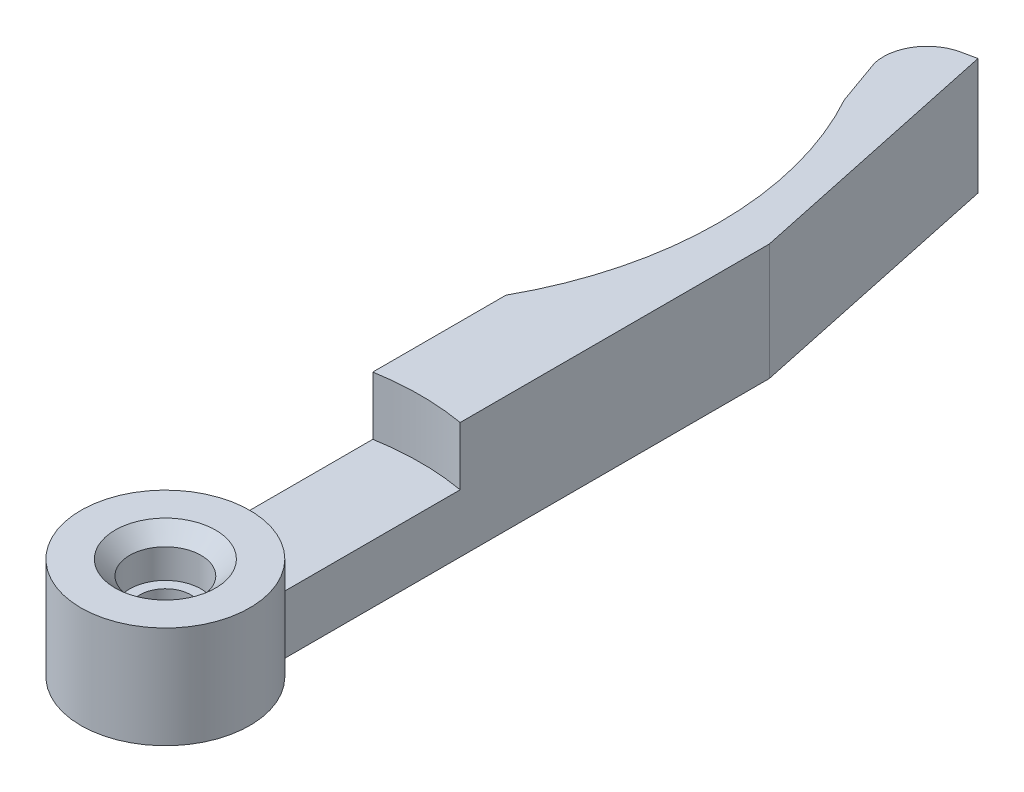
from build123d import *

# Parameters (mm, degrees)
BOSS_EXTRU_1_DEPTH      = 8
ESQUISSE2_R             = 2.45
ENL_V_MAT_EXTRU_1_DEPTH = 4
ENL_V_MAT_EXTRU_2_REACH = 59.094
ESQUISSE3_R             = 1.75
ESQUISSE4_R             = 3.75
ENL_V_MAT_EXTRU_3_DEPTH = 2.5
ENL_V_MAT_EXTRU_4_DEPTH = 4
ESQUISSE7_R             = 5.8
ENL_V_MAT_EXTRU_5_DEPTH = 1
CHANFREIN1_SIZE         = 1


with BuildPart() as part:
    # Esquisse1 → Boss.-Extru.1 (new body)
    with BuildSketch(Plane(origin=(0, 0, 0), x_dir=(1, 0, 0), z_dir=(0, 1, 0))):
        with BuildLine():
            Line((-3, 26.381049961), (-3, 4.963869458))
            ThreePointArc((-3, 4.963869458), (0, -5.8), (3, 4.963869458))
            Line((3, 4.963869458), (3, 38.463869458))
            Line((3, 38.463869458), (-0.867157449, 56.657414832))
            Line((-0.867157449, 56.657414832), (-1.84530505, 56.449503141))
            ThreePointArc((-1.84530505, 56.449503141), (-3.756758837, 55.119060789), (-4.140414176, 52.821988519))
            Line((-4.140414176, 52.821988519), (-3, 49.618950039))
            ThreePointArc((-3, 49.618950039), (0, 38), (-3, 26.381049961))
        make_face()
    extrude(amount=BOSS_EXTRU_1_DEPTH)

    # Esquisse2 → Enlèv. mat.-Extru.1 (cut)
    with BuildSketch(Plane(origin=(0, 8, 0), x_dir=(1, 0, 0), z_dir=(0, 1, 0))):
        with Locations(Location((0, 0, 0), (0, 0, 270))):
            Circle(ESQUISSE2_R)
    extrude(amount=-ENL_V_MAT_EXTRU_1_DEPTH, mode=Mode.SUBTRACT)

    # Esquisse3 → Enlèv. mat.-Extru.2 (cut, up to next)
    with BuildSketch(Plane(origin=(0, 4, 0), x_dir=(1, 0, 0), z_dir=(0, 1, 0)), mode=Mode.PRIVATE) as enl_v_mat_extru_2_sk1:
        with Locations(Location((0, 0, 0), (0, 0, 270))):
            Circle(ESQUISSE3_R)
    enl_v_mat_extru_2_tool1 = extrude(enl_v_mat_extru_2_sk1.sketch, amount=-ENL_V_MAT_EXTRU_2_REACH, mode=Mode.PRIVATE) & part.part
    add(enl_v_mat_extru_2_tool1.solids().sort_by_distance((0, 4, 0))[0], mode=Mode.SUBTRACT)

    # Esquisse4 → Enlèv. mat.-Extru.3 (cut)
    with BuildSketch(Plane.XZ):
        with Locations(Location((0, 0, 0), (0, 0, 270))):
            Circle(ESQUISSE4_R)
    extrude(amount=-ENL_V_MAT_EXTRU_3_DEPTH, mode=Mode.SUBTRACT)

    # Esquisse5 → Enlèv. mat.-Extru.4 (cut)
    with BuildSketch(Plane(origin=(0, 8, 0), x_dir=(1, 0, 0), z_dir=(0, 1, 0))):
        with BuildLine():
            Line((-3, 4.963869458), (-3, 17.24093965))
            ThreePointArc((-3, 17.24093965), (0, 17.5), (3, 17.24093965))
            Line((3, 17.24093965), (3, 4.963869458))
            ThreePointArc((3, 4.963869458), (0, 5.8), (-3, 4.963869458))
        make_face()
    extrude(amount=-ENL_V_MAT_EXTRU_4_DEPTH, mode=Mode.SUBTRACT)

    # Esquisse7 → Enlèv. mat.-Extru.5 (cut)
    with BuildSketch(Plane(origin=(0, 8, 0), x_dir=(1, 0, 0), z_dir=(0, 1, 0))):
        with Locations(Location((0, 0, 0), (0, 0, 58.852610078))):
            Circle(ESQUISSE7_R)
    extrude(amount=-ENL_V_MAT_EXTRU_5_DEPTH, mode=Mode.SUBTRACT)

    # Chanfrein1
    chanfrein1_edges = [part.edges().sort_by_distance(p)[0] for p in [
        (0, 7, -2.45),
    ]]
    chamfer(chanfrein1_edges, length=CHANFREIN1_SIZE)


solid = part.part
